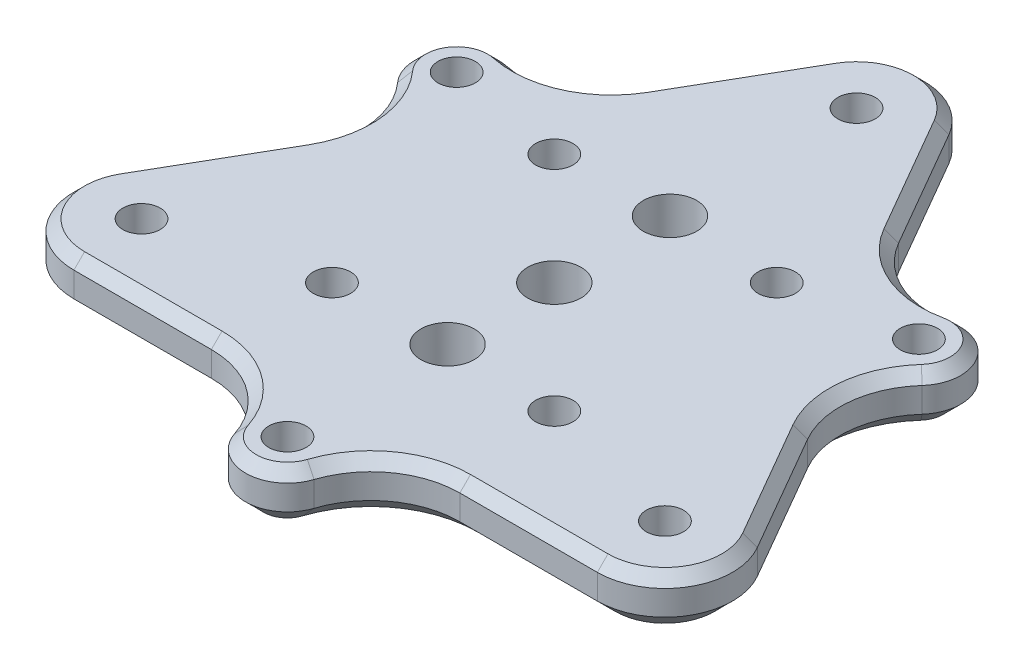
from build123d import *

# Parameters (mm, degrees)
SKETCH_1_R           = 5
SKETCH_1_R_2         = 2.1
EXTRUDE_1_DEPTH      = 6
FILLET_1_R           = 10
CHAMFER_1_SIZE       = 1.2
CHAMFER_3_SIZE       = 2
SKETCH_3_R           = 3
CUT_EXTRUDE_4_DEPTH  = 15
SKETCH_4_R           = 5
CUT_EXTRUDE_9_DEPTH  = 2
CUT_EXTRUDE_11_REACH = 6
SKETCH_5_R           = 2.1
CUT_EXTRUDE_12_REACH = 8
SKETCH_6_R           = 3
CHAMFER_4_SIZE       = 0.25
SKETCH_8_R           = 5
SKETCH_8_R_2         = 2.1
EXTRUDE_4_DEPTH      = 4
SKETCH_9_R           = 5
SKETCH_9_R_2         = 2.1
EXTRUDE_5_DEPTH      = 4


with BuildPart() as part:
    # ｽｹｯﾁ1 → ﾎﾞｽ - 押し出し1 (new body)
    with BuildSketch(Plane(origin=(0, 0, 0), x_dir=(1, 0, 0), z_dir=(0, 1, 0))):
        with BuildLine():
            Line((-18.940896534, 16.362624243), (-23.630762114, 19.070319398))
            ThreePointArc((-23.630762114, 19.070319398), (-30.051081511, 17.35), (-28.330762114, 10.929680602))
            Line((-28.330762114, 10.929680602), (-23.640896534, 8.221985447))
            Line((-23.640896534, 8.221985447), (-35.999999999, -13.18460969))
            ThreePointArc((-35.999999999, -13.18460969), (-35.999999999, -20.78460969), (-29.41820693, -24.58460969))
            Line((-29.41820693, -24.58460969), (-4.7, -24.58460969))
            Line((-4.7, -24.58460969), (-4.7, -30))
            ThreePointArc((-4.7, -30), (0, -34.7), (4.7, -30))
            Line((4.7, -30), (4.7, -24.58460969))
            Line((4.7, -24.58460969), (29.41820693, -24.58460969))
            ThreePointArc((29.41820693, -24.58460969), (35.999999999, -20.78460969), (35.999999999, -13.18460969))
            Line((35.999999999, -13.18460969), (23.640896534, 8.221985447))
            Line((23.640896534, 8.221985447), (28.330762114, 10.929680602))
            ThreePointArc((28.330762114, 10.929680602), (30.051081511, 17.35), (23.630762114, 19.070319398))
            Line((23.630762114, 19.070319398), (18.940896534, 16.362624243))
            Line((18.940896534, 16.362624243), (6.581793069, 37.76921938))
            ThreePointArc((6.581793069, 37.76921938), (0, 41.56921938), (-6.581793069, 37.76921938))
            Line((-6.581793069, 37.76921938), (-18.940896534, 16.362624243))
        make_face()
        with Locations((-29.41820693, -16.98460969)):
            Circle(SKETCH_1_R, mode=Mode.SUBTRACT)
        with Locations((0, -30)):
            Circle(SKETCH_1_R_2, mode=Mode.SUBTRACT)
        with Locations((29.41820693, -16.98460969)):
            Circle(SKETCH_1_R, mode=Mode.SUBTRACT)
        with Locations((-25.980762114, 15)):
            Circle(SKETCH_1_R_2, mode=Mode.SUBTRACT)
        with Locations((0, 33.96921938)):
            Circle(SKETCH_1_R, mode=Mode.SUBTRACT)
        with Locations((25.980762114, 15)):
            Circle(SKETCH_1_R_2, mode=Mode.SUBTRACT)
    extrude(amount=EXTRUDE_1_DEPTH)

    # ﾌｨﾚｯﾄ1
    fillet_1_edges = [part.edges().sort_by_distance(p)[0] for p in [
        (-23.640896534, 3, -8.221985447),
        (-18.940896534, 3, -16.362624243),
        (18.940896534, 3, -16.362624243),
        (23.640896534, 3, -8.221985447),
        (4.7, 3, 24.58460969),
        (-4.7, 3, 24.58460969),
    ]]
    fillet(fillet_1_edges, radius=FILLET_1_R)

    # 面取り1
    chamfer_1_edges = [part.edges().sort_by_distance(p)[0] for p in [
        (10.444646128, 6, -31.078561619),
        (0, 6, -41.56921938),
        (-32.137146939, 6, 6.493951929),
        (-35.999999999, 6, 20.78460969),
        (21.692500811, 6, 24.58460969),
        (35.999999999, 6, 20.78460969),
        (-30.051081511, 6, -17.35),
        (-10.444646128, 6, -31.078561619),
        (30.051081511, 6, -17.35),
        (32.137146939, 6, 6.493951929),
        (0, 6, 34.7),
        (-21.692500811, 6, 24.58460969),
        (-26.987767107, 6, -6.227022046),
        (-18.886642835, 6, -20.258580883),
        (18.886642835, 6, -20.258580883),
        (26.987767107, 6, -6.227022046),
        (8.101124272, 6, 26.485602929),
        (-8.101124272, 6, 26.485602929),
    ]]
    chamfer(chamfer_1_edges, length=CHAMFER_1_SIZE)

    # 面取り3
    chamfer_3_edges = [part.edges().sort_by_distance(p)[0] for p in [
        (35.999999999, 0, 20.78460969),
        (21.692500811, 0, 24.58460969),
        (-35.999999999, 0, 20.78460969),
        (-32.137146939, 0, 6.493951929),
        (0, 0, -41.56921938),
        (10.444646128, 0, -31.078561619),
        (-30.051081511, 0, -17.35),
        (-10.444646128, 0, -31.078561619),
        (30.051081511, 0, -17.35),
        (32.137146939, 0, 6.493951929),
        (0, 0, 34.7),
        (-21.692500811, 0, 24.58460969),
        (-26.987767107, 0, -6.227022046),
        (-18.886642835, 0, -20.258580883),
        (18.886642835, 0, -20.258580883),
        (26.987767107, 0, -6.227022046),
        (8.101124272, 0, 26.485602929),
        (-8.101124272, 0, 26.485602929),
    ]]
    chamfer(chamfer_3_edges, length=CHAMFER_3_SIZE)

    # ｽｹｯﾁ3 → ｶｯﾄ - 押し出し4 (cut)
    with BuildSketch(Plane.XZ):
        Circle(SKETCH_3_R)
    extrude(amount=-CUT_EXTRUDE_4_DEPTH, mode=Mode.SUBTRACT)

    # ｽｹｯﾁ4 → ｶｯﾄ - 押し出し9 (cut)
    with BuildSketch(Plane.XZ):
        with Locations((-12.5, 12.5)):
            Circle(SKETCH_4_R)
        with Locations((12.5, 12.5)):
            Circle(SKETCH_4_R)
        with Locations((12.5, -12.5)):
            Circle(SKETCH_4_R)
        with Locations((-12.5, -12.5)):
            Circle(SKETCH_4_R)
    extrude(amount=-CUT_EXTRUDE_9_DEPTH, mode=Mode.SUBTRACT)

    # ｽｹｯﾁ5 → ｶｯﾄ - 押し出し11 (cut, up to next)
    with BuildSketch(Plane.XZ.offset(-2), mode=Mode.PRIVATE) as cut_extrude_11_sk1:
        with Locations((12.5, 12.5)):
            Circle(SKETCH_5_R)
    cut_extrude_11_tool1 = extrude(cut_extrude_11_sk1.sketch, amount=-CUT_EXTRUDE_11_REACH, mode=Mode.PRIVATE) & part.part
    add(cut_extrude_11_tool1.solids().sort_by_distance((12.5, 2, 12.5))[0], mode=Mode.SUBTRACT)
    # ｽｹｯﾁ5 → ｶｯﾄ - 押し出し11 (cut, up to next)
    with BuildSketch(Plane.XZ.offset(-2), mode=Mode.PRIVATE) as cut_extrude_11_sk2:
        with Locations((-12.5, 12.5)):
            Circle(SKETCH_5_R)
    cut_extrude_11_tool2 = extrude(cut_extrude_11_sk2.sketch, amount=-CUT_EXTRUDE_11_REACH, mode=Mode.PRIVATE) & part.part
    add(cut_extrude_11_tool2.solids().sort_by_distance((-12.5, 2, 12.5))[0], mode=Mode.SUBTRACT)
    # ｽｹｯﾁ5 → ｶｯﾄ - 押し出し11 (cut, up to next)
    with BuildSketch(Plane.XZ.offset(-2), mode=Mode.PRIVATE) as cut_extrude_11_sk3:
        with Locations((-12.5, -12.5)):
            Circle(SKETCH_5_R)
    cut_extrude_11_tool3 = extrude(cut_extrude_11_sk3.sketch, amount=-CUT_EXTRUDE_11_REACH, mode=Mode.PRIVATE) & part.part
    add(cut_extrude_11_tool3.solids().sort_by_distance((-12.5, 2, -12.5))[0], mode=Mode.SUBTRACT)
    # ｽｹｯﾁ5 → ｶｯﾄ - 押し出し11 (cut, up to next)
    with BuildSketch(Plane.XZ.offset(-2), mode=Mode.PRIVATE) as cut_extrude_11_sk4:
        with Locations((12.5, -12.5)):
            Circle(SKETCH_5_R)
    cut_extrude_11_tool4 = extrude(cut_extrude_11_sk4.sketch, amount=-CUT_EXTRUDE_11_REACH, mode=Mode.PRIVATE) & part.part
    add(cut_extrude_11_tool4.solids().sort_by_distance((12.5, 2, -12.5))[0], mode=Mode.SUBTRACT)

    # ｽｹｯﾁ6 → ｶｯﾄ - 押し出し12 (cut, up to next)
    with BuildSketch(Plane(origin=(0, 0, 0), x_dir=(-1, 0, 0), z_dir=(0, -1, 0)), mode=Mode.PRIVATE) as cut_extrude_12_sk1:
        with Locations((0, 13)):
            Circle(SKETCH_6_R)
    cut_extrude_12_tool1 = extrude(cut_extrude_12_sk1.sketch, amount=-CUT_EXTRUDE_12_REACH, mode=Mode.PRIVATE) & part.part
    add(cut_extrude_12_tool1.solids().sort_by_distance((0, 0, -13))[0], mode=Mode.SUBTRACT)
    # ｽｹｯﾁ6 → ｶｯﾄ - 押し出し12 (cut, up to next)
    with BuildSketch(Plane(origin=(0, 0, 0), x_dir=(-1, 0, 0), z_dir=(0, -1, 0)), mode=Mode.PRIVATE) as cut_extrude_12_sk2:
        with Locations((0, -12)):
            Circle(SKETCH_6_R)
    cut_extrude_12_tool2 = extrude(cut_extrude_12_sk2.sketch, amount=-CUT_EXTRUDE_12_REACH, mode=Mode.PRIVATE) & part.part
    add(cut_extrude_12_tool2.solids().sort_by_distance((0, 0, 12))[0], mode=Mode.SUBTRACT)

    # 面取り4
    chamfer_4_edges = [part.edges().sort_by_distance(p)[0] for p in [
        (7.5, 0, -12.5),
        (-17.5, 0, -12.5),
        (-17.5, 0, 12.5),
        (7.5, 0, 12.5),
    ]]
    chamfer(chamfer_4_edges, length=CHAMFER_4_SIZE)

    # ｽｹｯﾁ8 → ﾎﾞｽ - 押し出し4 (add)
    with BuildSketch(Plane(origin=(0, 6, 0), x_dir=(1, 0, 0), z_dir=(0, 1, 0))):
        with Locations((29.41820693, -16.98460969)):
            Circle(SKETCH_8_R)
        with Locations((29.41820693, -16.98460969)):
            Circle(SKETCH_8_R_2, mode=Mode.SUBTRACT)
    extrude(amount=-EXTRUDE_4_DEPTH)

    # ｽｹｯﾁ9 → ﾎﾞｽ - 押し出し5 (add)
    with BuildSketch(Plane(origin=(0, 6, 0), x_dir=(1, 0, 0), z_dir=(0, 1, 0))):
        with Locations((0, 33.96921938)):
            Circle(SKETCH_9_R)
        with Locations((0, 33.96921938)):
            Circle(SKETCH_9_R_2, mode=Mode.SUBTRACT)
        with Locations((-29.41820693, -16.98460969)):
            Circle(SKETCH_9_R)
        with Locations((-29.41820693, -16.98460969)):
            Circle(SKETCH_9_R_2, mode=Mode.SUBTRACT)
    extrude(amount=-EXTRUDE_5_DEPTH)


solid = part.part
